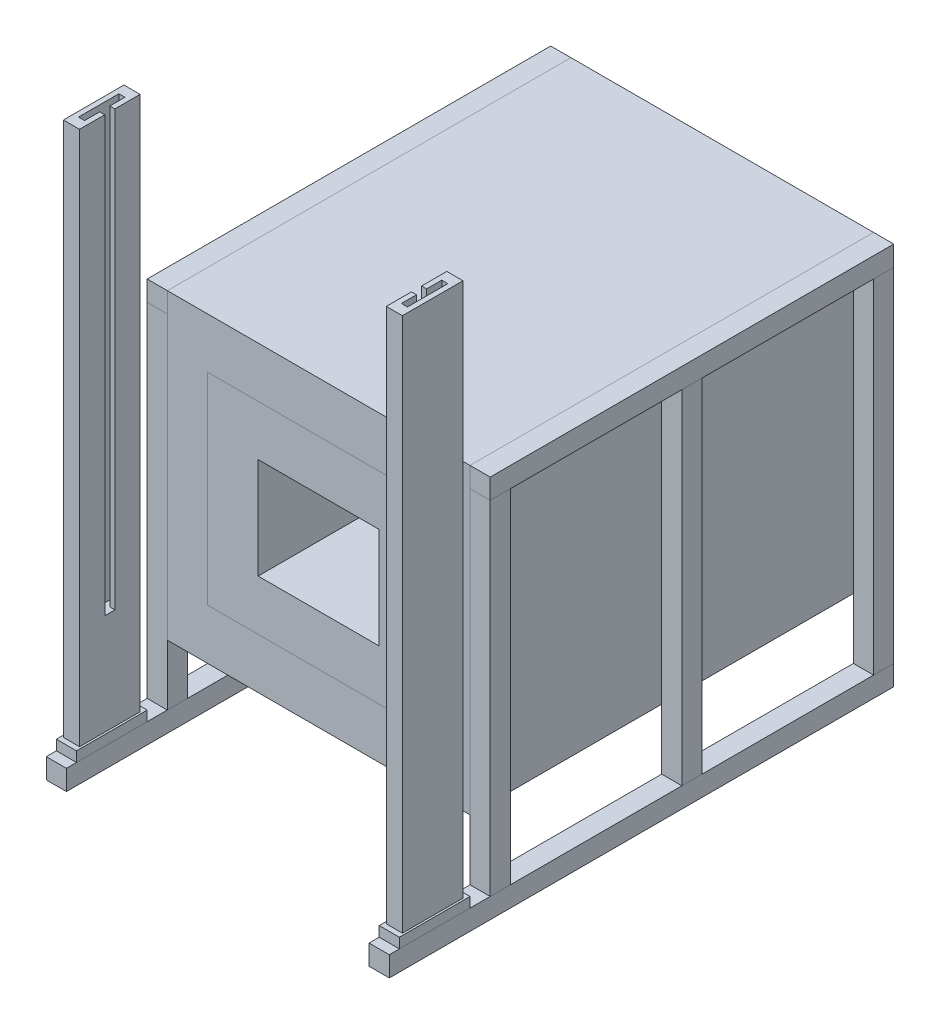
from build123d import *

# Parameters (mm, degrees)
SKETCH_1_W         = 1100
SKETCH_1_H         = 1000
SKETCH_1_W_2       = 600
SKETCH_1_H_2       = 500
EXTRUDE_1_DEPTH    = 1300
SKETCH_2_W         = 600
SKETCH_2_H         = 100
EXTRUDE_2_DEPTH    = 500
SKETCH_3_W         = 1500
SKETCH_3_H         = 1500
SKETCH_3_W_2       = 1100
SKETCH_3_H_2       = 1000
EXTRUDE_3_DEPTH    = 2000
SKETCH_4_W         = 1100
SKETCH_4_H         = 100
EXTRUDE_4_DEPTH    = 1000
SKETCH_7_W         = 100
SKETCH_7_H         = 100
EXTRUDE_7_DEPTH    = 2000
EXTRUDE_7_2_DEPTH  = 2000
EXTRUDE_7_3_DEPTH  = 2000
EXTRUDE_7_4_DEPTH  = 2000
SKETCH_7_2_W       = 100
SKETCH_7_2_H       = 100
EXTRUDE_8_DEPTH    = 500
SKETCH_8_W         = 100
SKETCH_8_H         = 100
EXTRUDE_9_DEPTH    = 1700
EXTRUDE_9_2_DEPTH  = 1700
EXTRUDE_9_3_DEPTH  = 1700
EXTRUDE_9_4_DEPTH  = 1700
EXTRUDE_9_5_DEPTH  = 1700
EXTRUDE_9_6_DEPTH  = 1700
SKETCH_9_W         = 100
SKETCH_9_H         = 350
EXTRUDE_10_DEPTH   = 50
EXTRUDE_10_2_DEPTH = 50
EXTRUDE_11_DEPTH   = 2700
EXTRUDE_12_DEPTH   = 500


with BuildPart() as part:
    # Эскиз1 → Бобышка-Вытянуть1 (new body)
    with BuildSketch(Plane.XY):
        Rectangle(SKETCH_1_W, SKETCH_1_H)
        Rectangle(SKETCH_1_W_2, SKETCH_1_H_2, mode=Mode.SUBTRACT)
    extrude(amount=-EXTRUDE_1_DEPTH)

    # Эскиз2 → Бобышка-Вытянуть2 (add)
    with BuildSketch(Plane(origin=(0, -250, 0), x_dir=(1, 0, 0), z_dir=(0, 1, 0))):
        with Locations((0, 1250)):
            Rectangle(SKETCH_2_W, SKETCH_2_H)
    extrude(amount=EXTRUDE_2_DEPTH)


with BuildPart() as body_2:
    # Эскиз3 → Бобышка-Вытянуть3 (new body)
    with BuildSketch(Plane.XY):
        Rectangle(SKETCH_3_W, SKETCH_3_H)
        Rectangle(SKETCH_3_W_2, SKETCH_3_H_2, mode=Mode.SUBTRACT)
    extrude(amount=-EXTRUDE_3_DEPTH)

    # Эскиз4 → Бобышка-Вытянуть4 (add)
    with BuildSketch(Plane(origin=(0, -500, 0), x_dir=(1, 0, 0), z_dir=(0, 1, 0))):
        with Locations((0, 1950)):
            Rectangle(SKETCH_4_W, SKETCH_4_H)
    extrude(amount=EXTRUDE_4_DEPTH)


with BuildPart() as body_3:
    # Эскиз7 → Бобышка-Вытянуть7 (new body)
    with BuildSketch(Plane.XY):
        with Locations((-800, 700)):
            Rectangle(SKETCH_7_W, SKETCH_7_H)
    extrude(amount=-EXTRUDE_7_DEPTH)


with BuildPart() as body_4:
    # Эскиз7 → Extrude 7 2 (new body)
    with BuildSketch(Plane.XY):
        with Locations((-800, -1100)):
            Rectangle(SKETCH_7_W, SKETCH_7_H)
    extrude(amount=-EXTRUDE_7_2_DEPTH)



with BuildPart() as body_5:
    # Эскиз7 → Extrude 7 3 (new body)
    with BuildSketch(Plane.XY):
        with Locations((800, -1100)):
            Rectangle(SKETCH_7_W, SKETCH_7_H)
    extrude(amount=-EXTRUDE_7_3_DEPTH)


with BuildPart() as body_6:
    # Эскиз7 → Extrude 7 4 (new body)
    with BuildSketch(Plane.XY):
        with Locations((800, 700)):
            Rectangle(SKETCH_7_W, SKETCH_7_H)
    extrude(amount=-EXTRUDE_7_4_DEPTH)


with BuildPart() as body_4_1:
    add(body_4.part)

    add(body_5.part)  # Бобышка-Вытянуть8 merges body 5
    # Эскиз7<2> → Бобышка-Вытянуть8 (add)
    with BuildSketch(Plane.XY):
        with Locations((-800, -1100)):
            Rectangle(SKETCH_7_2_W, SKETCH_7_2_H)
        with Locations((800, -1100)):
            Rectangle(SKETCH_7_2_W, SKETCH_7_2_H)
    extrude(amount=EXTRUDE_8_DEPTH)


with BuildPart() as body_6_2:
    # Эскиз8 → Бобышка-Вытянуть9 (new body)
    with BuildSketch(Plane.XZ.offset(-650)):
        with Locations((800, -50)):
            Rectangle(SKETCH_8_W, SKETCH_8_H)
    extrude(amount=EXTRUDE_9_DEPTH)


with BuildPart() as body_7:
    # Эскиз8 → Extrude 9 2 (new body)
    with BuildSketch(Plane.XZ.offset(-650)):
        with Locations((800, -1950)):
            Rectangle(SKETCH_8_W, SKETCH_8_H)
    extrude(amount=EXTRUDE_9_2_DEPTH)


with BuildPart() as body_8:
    # Эскиз8 → Extrude 9 3 (new body)
    with BuildSketch(Plane.XZ.offset(-650)):
        with Locations((800, -1000)):
            Rectangle(SKETCH_8_W, SKETCH_8_H)
    extrude(amount=EXTRUDE_9_3_DEPTH)


with BuildPart() as body_9:
    # Эскиз8 → Extrude 9 4 (new body)
    with BuildSketch(Plane.XZ.offset(-650)):
        with Locations((-800, -1000)):
            Rectangle(SKETCH_8_W, SKETCH_8_H)
    extrude(amount=EXTRUDE_9_4_DEPTH)


with BuildPart() as body_10:
    # Эскиз8 → Extrude 9 5 (new body)
    with BuildSketch(Plane.XZ.offset(-650)):
        with Locations((-800, -1950)):
            Rectangle(SKETCH_8_W, SKETCH_8_H)
    extrude(amount=EXTRUDE_9_5_DEPTH)


with BuildPart() as body_11:
    # Эскиз8 → Extrude 9 6 (new body)
    with BuildSketch(Plane.XZ.offset(-650)):
        with Locations((-800, -50)):
            Rectangle(SKETCH_8_W, SKETCH_8_H)
    extrude(amount=EXTRUDE_9_6_DEPTH)


with BuildPart() as body_12:
    # Эскиз9 → Бобышка-Вытянуть10 (new body)
    with BuildSketch(Plane(origin=(0, -1050, 0), x_dir=(1, 0, 0), z_dir=(0, 1, 0))):
        with Locations((800, -275)):
            Rectangle(SKETCH_9_W, SKETCH_9_H)
        Polygon((760, -125), (840, -125), (840, -425), (760, -425), (760, -300), (785, -300), (785, -375), (815, -375), (815, -175), (785, -175), (785, -250), (760, -250), align=None, mode=Mode.SUBTRACT)
    extrude(amount=EXTRUDE_10_DEPTH)


with BuildPart() as body_13:
    # Эскиз9 → Extrude 10 2 (new body)
    with BuildSketch(Plane(origin=(0, -1050, 0), x_dir=(1, 0, 0), z_dir=(0, 1, 0))):
        with Locations((-800, -275)):
            Rectangle(SKETCH_9_W, SKETCH_9_H)
        Polygon((-760, -250), (-760, -125), (-840, -125), (-840, -425), (-760, -425), (-760, -300), (-785, -300), (-785, -375), (-815, -375), (-815, -175), (-785, -175), (-785, -250), align=None, mode=Mode.SUBTRACT)
    extrude(amount=EXTRUDE_10_2_DEPTH)


    add(body_12.part)  # Бобышка-Вытянуть11 merges body 12
    # Эскиз9<2> → Бобышка-Вытянуть11 (add)
    with BuildSketch(Plane(origin=(0, -1050, 0), x_dir=(1, 0, 0), z_dir=(0, 1, 0))):
        Polygon((760, -250), (760, -125), (840, -125), (840, -425), (760, -425), (760, -300), (785, -300), (785, -375), (815, -375), (815, -175), (785, -175), (785, -250), align=None)
        Polygon((-760, -250), (-760, -125), (-840, -125), (-840, -425), (-760, -425), (-760, -300), (-785, -300), (-785, -375), (-815, -375), (-815, -175), (-785, -175), (-785, -250), align=None)
    extrude(amount=EXTRUDE_11_DEPTH)

    # Эскиз10 → Бобышка-Вытянуть12 (add)
    with BuildSketch(Plane(origin=(0, -1000, 0), x_dir=(1, 0, 0), z_dir=(0, 1, 0))):
        Polygon((815, -375), (815, -175), (785, -175), (785, -250), (760, -250), (760, -300), (785, -300), (785, -375), align=None)
        Polygon((-760, -250), (-785, -250), (-785, -175), (-815, -175), (-815, -375), (-785, -375), (-785, -300), (-760, -300), align=None)
    extrude(amount=EXTRUDE_12_DEPTH)


solid = Compound([part.part, body_2.part, body_3.part, body_6.part, body_4_1.part, body_6_2.part, body_7.part, body_8.part, body_9.part, body_10.part, body_11.part, body_13.part])
